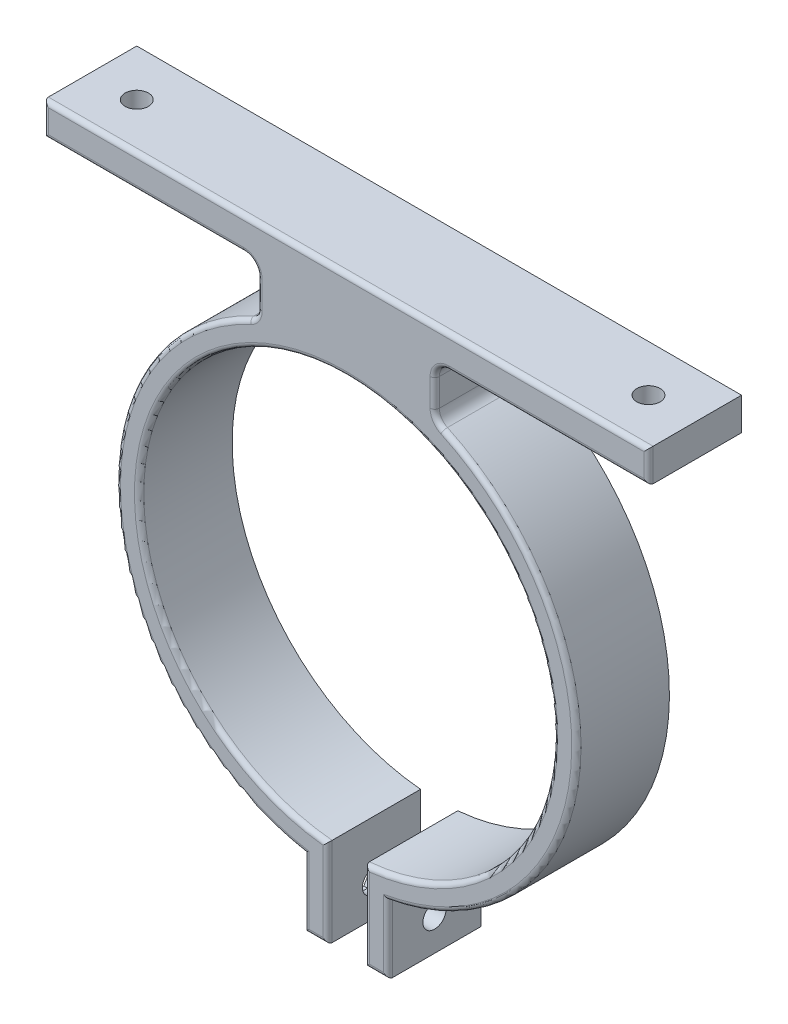
from build123d import *

# Parameters (mm, degrees)
BOSS_EXTRUDE1_DEPTH = 20
FILLET1_R           = 3
SKETCH2_R           = 2.5
CUT_EXTRUDE1_DEPTH  = 138.861426252
SKETCH3_R           = 2.5
CUT_EXTRUDE2_DEPTH  = 100.572096995
SKETCH3_4_R         = 2.5
CUT_EXTRUDE3_DEPTH  = 3.175
FILLET2_R           = 1


with BuildPart() as part:
    # Sketch1 → Boss-Extrude1 (new body)
    with BuildSketch(Plane.XY):
        with BuildLine():
            ThreePointArc((-4, -44.319860108), (0, 44.5), (4, -44.319860108))
            Line((4, -44.319860108), (4, -63.369860108))
            Line((4, -63.369860108), (9, -63.369860108))
            Line((9, -63.369860108), (9, -48.674942219))
            ThreePointArc((9, -48.674942219), (49.221622989, -5.242311542), (19.05, 45.68749829))
            Line((19.05, 45.68749829), (19.05, 56.55))
            Line((19.05, 56.55), (65, 56.55))
            Line((65, 56.55), (65, 63.55))
            Line((65, 63.55), (-65, 63.55))
            Line((-65, 63.55), (-65, 56.55))
            Line((-65, 56.55), (-19.05, 56.55))
            Line((-19.05, 56.55), (-19.05, 45.68749829))
            ThreePointArc((-19.05, 45.68749829), (-49.221622989, -5.242311542), (-9, -48.674942219))
            Line((-9, -48.674942219), (-9, -63.369860108))
            Line((-9, -63.369860108), (-4, -63.369860108))
            Line((-4, -63.369860108), (-4, -44.319860108))
        make_face()
    extrude(amount=BOSS_EXTRUDE1_DEPTH)

    # Fillet1
    fillet1_edges = [part.edges().sort_by_distance(p)[0] for p in [
        (19.05, 45.68749829, 10),
        (19.05, 56.55, 10),
        (-19.05, 45.68749829, 10),
        (-19.05, 56.55, 10),
    ]]
    fillet(fillet1_edges, radius=FILLET1_R)

    # Sketch2 → Cut-Extrude1 (cut, through all)
    with BuildSketch(Plane(origin=(0, 56.55, 0), x_dir=(-1, 0, 0), z_dir=(0, -1, 0))):
        with Locations((55, -10)):
            Circle(SKETCH2_R)
        with Locations((-55, -10)):
            Circle(SKETCH2_R)
    extrude(amount=-CUT_EXTRUDE1_DEPTH, mode=Mode.SUBTRACT)

    # Sketch3 → Cut-Extrude2 (cut, through all)
    with BuildSketch(Plane.ZY.offset(9)):
        with Locations((10, -56.369860108)):
            Circle(SKETCH3_R)
    extrude(amount=-CUT_EXTRUDE2_DEPTH, mode=Mode.SUBTRACT)

    # Sketch3_4 → Cut-Extrude3 (cut)
    with BuildSketch(Plane.ZY.offset(9)):
        Polygon((15.600297611, -56.369860108), (12.800148806, -51.519860108), (7.199851194, -51.519860108), (4.399702389, -56.369860108), (7.199851194, -61.219860108), (12.800148806, -61.219860108), align=None)
        with Locations((10, -56.369860108)):
            Circle(SKETCH3_4_R, mode=Mode.SUBTRACT)
    extrude(amount=-CUT_EXTRUDE3_DEPTH, mode=Mode.SUBTRACT)

    # Fillet2
    fillet2_edges = [part.edges().sort_by_distance(p)[0] for p in [
        (-65, 60.05, 20),
        (0, 63.55, 20),
        (65, 60.05, 20),
        (43.525, 56.55, 20),
        (19.928679656, 55.671320344, 20),
        (19.05, 50.59750774, 20),
        (19.522155068, 46.029466037, 20),
        (49.1118994, -6.186383215, 20),
        (9, -56.022401163, 20),
        (6.5, -63.369860108, 20),
        (4, -53.844860108, 20),
        (0, 44.5, 20),
        (-4, -53.844860108, 20),
        (-6.5, -63.369860108, 20),
        (-9, -56.022401163, 20),
        (-49.1118994, -6.186383215, 20),
        (-19.522155068, 46.029466037, 20),
        (-19.05, 50.59750774, 20),
        (-19.928679656, 55.671320344, 20),
        (-43.525, 56.55, 20),
    ]]
    fillet(fillet2_edges, radius=FILLET2_R)


solid = part.part
